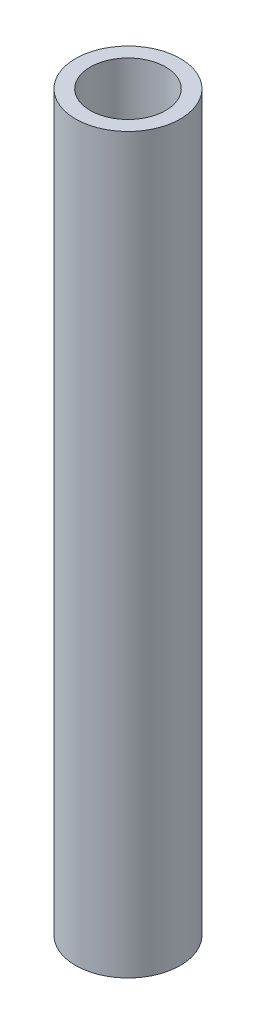
from build123d import *

# Parameters (mm, degrees)
SKETCH1_R           = 3.175
SKETCH1_R_2         = 2.286
BOSS_EXTRUDE1_DEPTH = 44.45


with BuildPart() as part:
    # Sketch1 → Boss-Extrude1 (new body)
    with BuildSketch(Plane(origin=(0, 0, 0), x_dir=(1, 0, 0), z_dir=(0, 1, 0))):
        Circle(SKETCH1_R)
        Circle(SKETCH1_R_2, mode=Mode.SUBTRACT)
    extrude(amount=BOSS_EXTRUDE1_DEPTH)


solid = part.part
